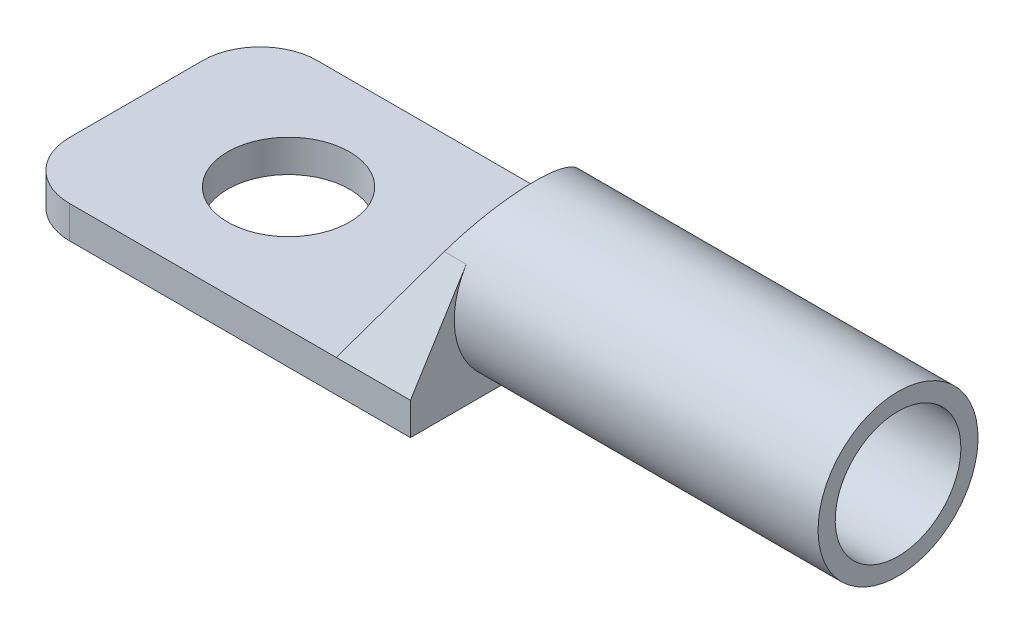
from build123d import *

# Parameters (mm, degrees)
CROQUIS1_W              = 40
CROQUIS1_H              = 13
SALIENTE_EXTRUIR1_DEPTH = 13
CROQUIS2_R              = 3.3
CORTAR_EXTRUIR1_DEPTH   = 17
CROQUIS3_R              = 3.2
CORTAR_EXTRUIR4_DEPTH   = 19
CROQUIS7_W              = 17
CROQUIS7_H              = 13
CORTAR_EXTRUIR5_DEPTH   = 9
CROQUIS8_OUTSIDE_W      = 23.804
CROQUIS8_OUTSIDE_H      = 23.804
CROQUIS8_OUTSIDE_R      = 4.2
CORTAR_EXTRUIR6_DEPTH   = 19.1
CROQUIS9_W              = 3.9
CROQUIS9_H              = 13
CORTAR_EXTRUIR7_DEPTH   = 2.3
CROQUIS10_W             = 20.9
CROQUIS10_H             = 13
CORTAR_EXTRUIR8_DEPTH   = 2.3
CORTAR_EXTRUIR9_DEPTH   = 22.3
CORTAR_EXTRUIR10_DEPTH  = 22.3
CORTAR_EXTRUIR11_DEPTH  = 22.3
CORTAR_EXTRUIR12_DEPTH  = 32.3
REDONDEO1_R             = 3


with BuildPart() as part:
    # Croquis1 → Saliente-Extruir1 (new body)
    with BuildSketch(Plane.XY):
        with Locations((20, 6.5)):
            Rectangle(CROQUIS1_W, CROQUIS1_H)
    extrude(amount=SALIENTE_EXTRUIR1_DEPTH)

    # Croquis2 → Cortar-Extruir1 (cut)
    with BuildSketch(Plane(origin=(40, 0, 0), x_dir=(0, 0, -1), z_dir=(1, 0, 0))):
        with Locations((-6.5, 6.5)):
            Circle(CROQUIS2_R)
    extrude(amount=-CORTAR_EXTRUIR1_DEPTH, mode=Mode.SUBTRACT)

    # Croquis3 → Cortar-Extruir4 (cut)
    with BuildSketch(Plane(origin=(0, 13, 0), x_dir=(1, 0, 0), z_dir=(0, 1, 0))):
        with Locations((8, -6.5)):
            Circle(CROQUIS3_R)
    extrude(amount=-CORTAR_EXTRUIR4_DEPTH, mode=Mode.SUBTRACT)

    # Croquis7 → Cortar-Extruir5 (cut)
    with BuildSketch(Plane(origin=(0, 13, 0), x_dir=(1, 0, 0), z_dir=(0, 1, 0))):
        with Locations((8.5, -6.5)):
            Rectangle(CROQUIS7_W, CROQUIS7_H)
    extrude(amount=-CORTAR_EXTRUIR5_DEPTH, mode=Mode.SUBTRACT)

    # Croquis8 outside → Cortar-Extruir6 (cut)
    with BuildSketch(Plane(origin=(40, 0, 0), x_dir=(0, 0, -1), z_dir=(1, 0, 0))):
        with Locations((-6.5, 6.5)):
            Rectangle(CROQUIS8_OUTSIDE_W, CROQUIS8_OUTSIDE_H)
        with Locations((-6.5, 6.5)):
            Circle(CROQUIS8_OUTSIDE_R, mode=Mode.SUBTRACT)
    extrude(amount=-CORTAR_EXTRUIR6_DEPTH, mode=Mode.SUBTRACT)

    # Croquis9 → Cortar-Extruir7 (cut)
    with BuildSketch(Plane(origin=(0, 13, 0), x_dir=(1, 0, 0), z_dir=(0, 1, 0))):
        with Locations((18.95, -6.5)):
            Rectangle(CROQUIS9_W, CROQUIS9_H)
    extrude(amount=-CORTAR_EXTRUIR7_DEPTH, mode=Mode.SUBTRACT)

    # Croquis10 → Cortar-Extruir8 (cut)
    with BuildSketch(Plane.XZ):
        with Locations((10.45, 6.5)):
            Rectangle(CROQUIS10_W, CROQUIS10_H)
    extrude(amount=-CORTAR_EXTRUIR8_DEPTH, mode=Mode.SUBTRACT)

    # Croquis11 → Cortar-Extruir9 (cut)
    with BuildSketch(Plane.XY.offset(13)):
        Polygon((17, 4), (17, 10.7), (20.9, 10.7), align=None)
    extrude(amount=-CORTAR_EXTRUIR9_DEPTH, mode=Mode.SUBTRACT)

    # Croquis13 → Cortar-Extruir10 (cut)
    with BuildSketch(Plane(origin=(20.9, 0, 0), x_dir=(0, 0, -1), z_dir=(1, 0, 0))):
        Polygon((-13, 4), (-13, 10.7), (-8.834314401, 10.7), align=None)
    extrude(amount=-CORTAR_EXTRUIR10_DEPTH, mode=Mode.SUBTRACT)

    # Croquis14 → Cortar-Extruir11 (cut)
    with BuildSketch(Plane(origin=(20.9, 0, 0), x_dir=(0, 0, -1), z_dir=(1, 0, 0))):
        Polygon((0, 4), (0, 10.7), (-4.165524435, 10.7), align=None)
    extrude(amount=-CORTAR_EXTRUIR11_DEPTH, mode=Mode.SUBTRACT)

    # Croquis15 → Cortar-Extruir12 (cut)
    with BuildSketch(Plane(origin=(40, 0, 0), x_dir=(0, 0, -1), z_dir=(1, 0, 0))):
        with BuildLine():
            Line((-10.06680245, 8.717638448), (-11.135301445, 9.381971415))
            ThreePointArc((-11.135301445, 9.381971415), (-6.499952655, 11.958184563), (-1.864648558, 9.381891))
            Line((-1.864648558, 9.381891), (-2.933159079, 8.717576569))
            ThreePointArc((-2.933159079, 8.717576569), (-6.499963568, 10.7), (-10.06680245, 8.717638448))
        make_face()
    extrude(amount=-CORTAR_EXTRUIR12_DEPTH, mode=Mode.SUBTRACT)

    # Redondeo1
    redondeo1_edges = [part.edges().sort_by_distance(p)[0] for p in [
        (0, 3.15, 0),
        (0, 3.15, 13),
    ]]
    fillet(redondeo1_edges, radius=REDONDEO1_R)


solid = part.part
